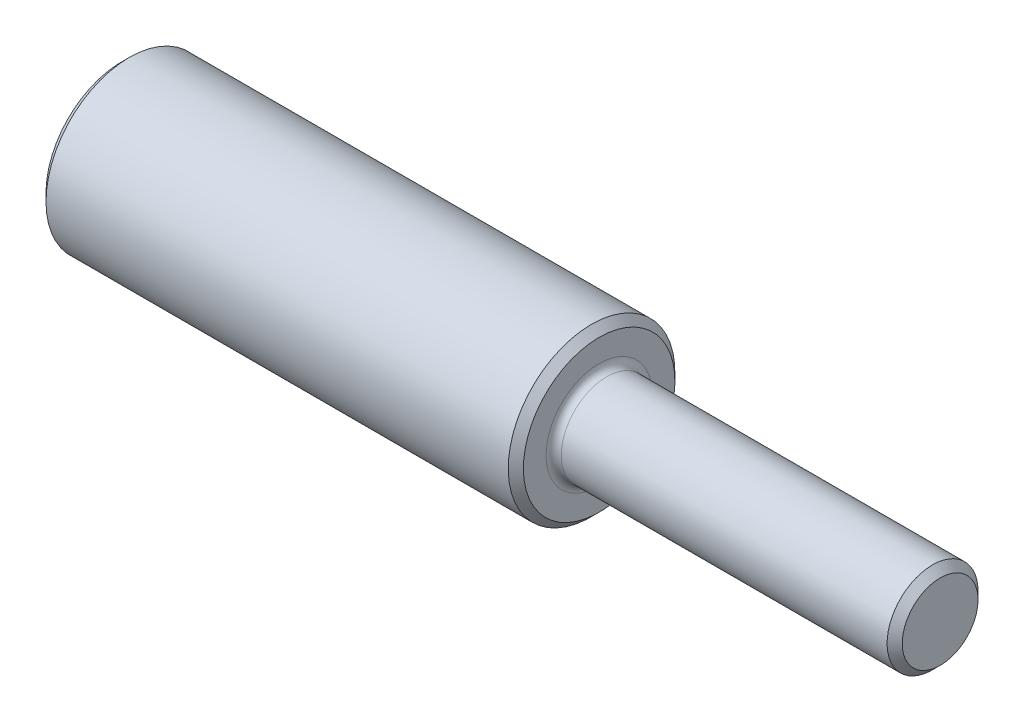
from build123d import *

# Parameters (mm, degrees)
CUT_EXTRUDE1_DEPTH = 35
CHAMFER2_SIZE      = 1


with BuildPart() as part:
    # Sketch1 → Revolve1 (revolve)
    with BuildSketch(Plane.XY):
        with BuildLine():
            Line((0, 0), (0, 11))
            Line((0, 11), (63, 11))
            Line((63, 11), (63, 7))
            ThreePointArc((63, 7), (63.292893219, 6.292893219), (64, 6))
            Line((64, 6), (108, 6))
            Line((108, 6), (108, 0))
            Line((108, 0), (0, 0))
        make_face()
    revolve(axis=Axis((113.833823868, 0, 0), (-1, 0, 0)))

    # Sketch2 → Cut-Extrude1 (cut)
    with BuildSketch(Plane.ZY):
        with BuildLine():
            Line((-9.3, -2.5), (-6.538348415, -2.5))
            ThreePointArc((-6.538348415, -2.5), (7, 0), (-6.538348415, 2.5))
            Line((-6.538348415, 2.5), (-9.3, 2.5))
            Line((-9.3, 2.5), (-9.3, -2.5))
        make_face()
    extrude(amount=-CUT_EXTRUDE1_DEPTH, mode=Mode.SUBTRACT)

    # Chamfer2
    chamfer2_edges = [part.edges().sort_by_distance(p)[0] for p in [
        (0, 0, 7),
        (0, -11, 0),
        (63, -11, 0),
        (108, -6, 0),
    ]]
    chamfer(chamfer2_edges, length=CHAMFER2_SIZE)


solid = part.part
